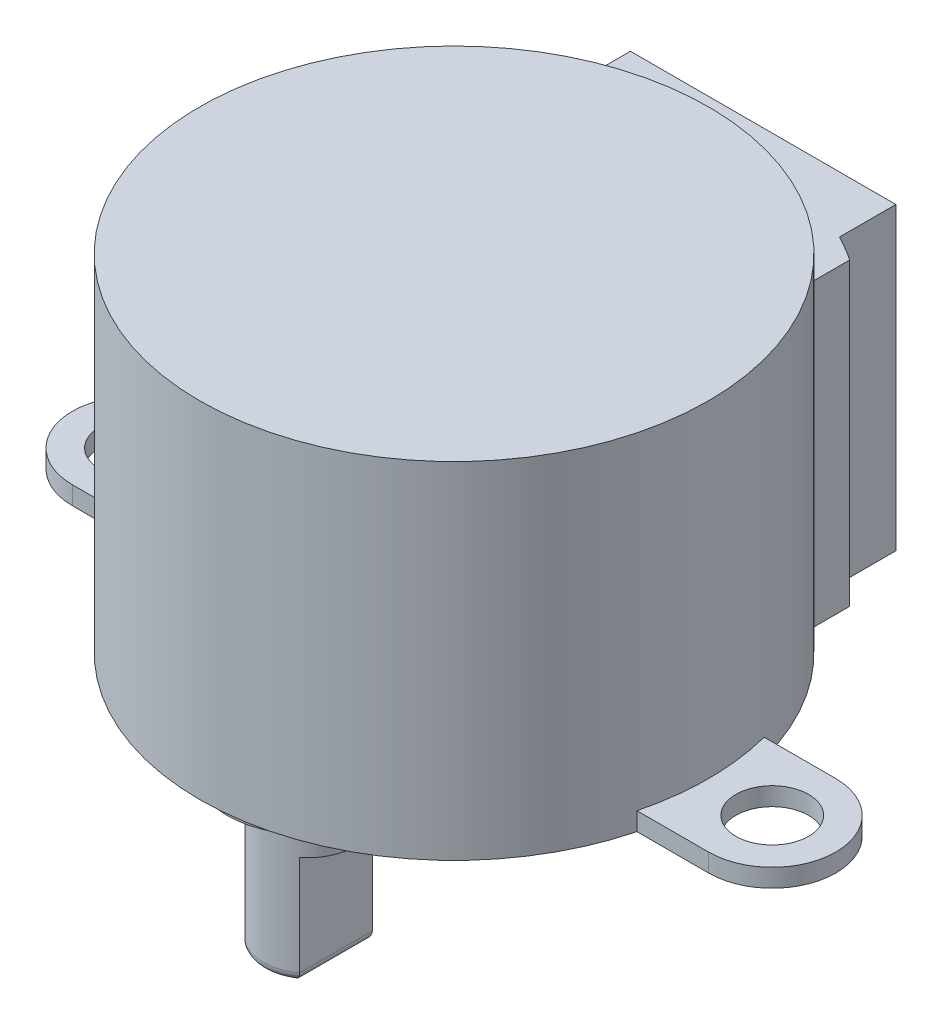
from build123d import *

# Parameters (mm, degrees)
SKETCH1_R           = 14
BOSS_EXTRUDE1_DEPTH = 19
BOSS_EXTRUDE2_DEPTH = 16.5
SKETCH3_R           = 2
BOSS_EXTRUDE3_DEPTH = 1
SKETCH4_R           = 4.5
BOSS_EXTRUDE4_DEPTH = 1.5
SKETCH5_R           = 2.5
BOSS_EXTRUDE5_DEPTH = 2.5
BOSS_EXTRUDE6_DEPTH = 6
FILLET1_R           = 0.5
SKETCH7_R           = 0.5
CUT_EXTRUDE1_DEPTH  = 1


with BuildPart() as part:
    # Sketch1 → Boss-Extrude1 (new body)
    with BuildSketch(Plane(origin=(0, 0, 0), x_dir=(1, 0, 0), z_dir=(0, 1, 0))):
        Circle(SKETCH1_R)
    extrude(amount=BOSS_EXTRUDE1_DEPTH)

    # Sketch2 → Boss-Extrude2 (add)
    with BuildSketch(Plane(origin=(0, 0, 0), x_dir=(1, 0, 0), z_dir=(0, 1, 0))):
        with BuildLine():
            Line((7.3, 17), (-7.3, 17))
            Line((-7.3, 17), (-7.3, 13.902200296))
            ThreePointArc((-7.3, 13.902200296), (-7.99785811, 13.51278797), (-8.675, 13.088374539))
            Line((-8.675, 13.088374539), (-8.675, 10.988374539))
            ThreePointArc((-8.675, 10.988374539), (0, 14), (8.675, 10.988374539))
            Line((8.675, 10.988374539), (8.675, 13.088374539))
            ThreePointArc((8.675, 13.088374539), (7.99785811, 13.51278797), (7.3, 13.902200296))
            Line((7.3, 13.902200296), (7.3, 17))
        make_face()
    extrude(amount=BOSS_EXTRUDE2_DEPTH)

    # Sketch3 → Boss-Extrude3 (add)
    with BuildSketch(Plane(origin=(0, 0, 0), x_dir=(1, 0, 0), z_dir=(0, 1, 0))):
        with BuildLine():
            Line((-17.5, 3.5), (-13.555441712, 3.5))
            ThreePointArc((-13.555441712, 3.5), (-14, 0), (-13.555441712, -3.5))
            Line((-13.555441712, -3.5), (-17.5, -3.5))
            ThreePointArc((-17.5, -3.5), (-21, 0), (-17.5, 3.5))
        make_face()
        with Locations((-17.5, 0)):
            Circle(SKETCH3_R, mode=Mode.SUBTRACT)
        with BuildLine():
            Line((17.5, 3.5), (13.555441712, 3.5))
            ThreePointArc((13.555441712, 3.5), (14, 0), (13.555441712, -3.5))
            Line((13.555441712, -3.5), (17.5, -3.5))
            ThreePointArc((17.5, -3.5), (21, 0), (17.5, 3.5))
        make_face()
        with Locations((17.5, 0)):
            Circle(SKETCH3_R, mode=Mode.SUBTRACT)
    extrude(amount=BOSS_EXTRUDE3_DEPTH)

    # Sketch4 → Boss-Extrude4 (add)
    with BuildSketch(Plane.XZ):
        with Locations((0, 8)):
            Circle(SKETCH4_R)
    extrude(amount=BOSS_EXTRUDE4_DEPTH)

    # Sketch5 → Boss-Extrude5 (add)
    with BuildSketch(Plane.XZ.offset(1.5)):
        with Locations((0, 8)):
            Circle(SKETCH5_R)
    extrude(amount=BOSS_EXTRUDE5_DEPTH)

    # Sketch6 → Boss-Extrude6 (add)
    with BuildSketch(Plane.XZ.offset(4)):
        with BuildLine():
            Line((-1.5, 10), (-1.5, 6))
            ThreePointArc((-1.5, 6), (0, 5.5), (1.5, 6))
            Line((1.5, 6), (1.5, 10))
            ThreePointArc((1.5, 10), (0, 10.5), (-1.5, 10))
        make_face()
    extrude(amount=BOSS_EXTRUDE6_DEPTH)

    # Fillet1
    fillet1_edges = [part.edges().sort_by_distance(p)[0] for p in [
        (0, -10, 10.5),
        (-1.5, -10, 8),
        (0, -10, 5.5),
        (1.5, -10, 8),
    ]]
    fillet(fillet1_edges, radius=FILLET1_R)

    # Sketch7 → Cut-Extrude1 (cut)
    with BuildSketch(Plane.XZ.offset(10)):
        with Locations((0, 8)):
            Circle(SKETCH7_R)
    extrude(amount=-CUT_EXTRUDE1_DEPTH, mode=Mode.SUBTRACT)


solid = part.part
